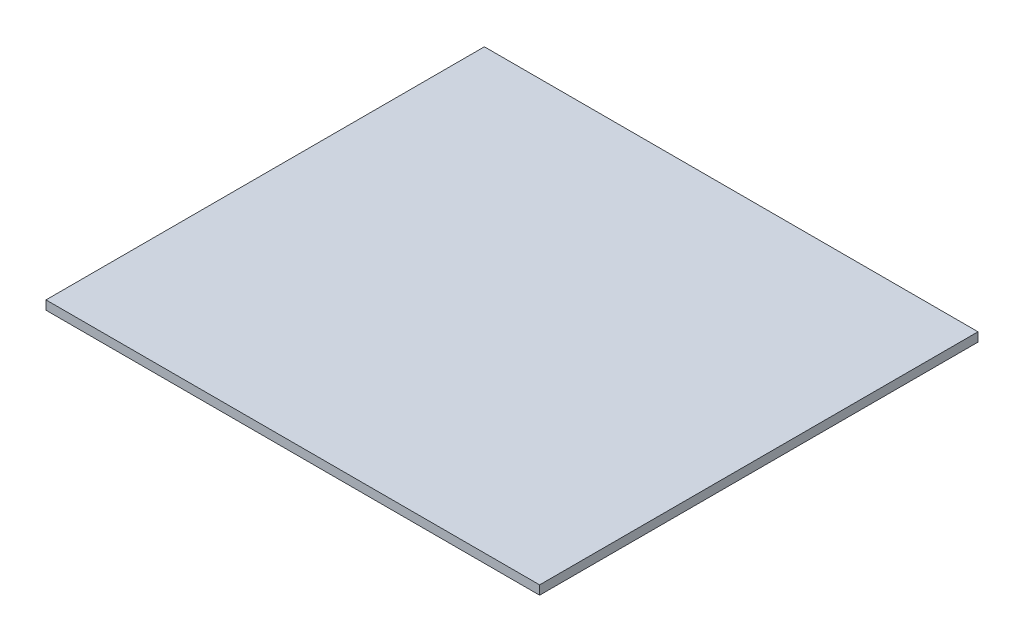
from build123d import *

# Parameters (mm, degrees)
SKETCH1_W           = 71.5
SKETCH1_H           = 63.5
BOSS_EXTRUDE1_DEPTH = 1.3


with BuildPart() as part:
    # Sketch1 → Boss-Extrude1 (new body)
    with BuildSketch(Plane(origin=(0, 0, 0), x_dir=(1, 0, 0), z_dir=(0, 1, 0))):
        Rectangle(SKETCH1_W, SKETCH1_H)
    extrude(amount=BOSS_EXTRUDE1_DEPTH)


solid = part.part
